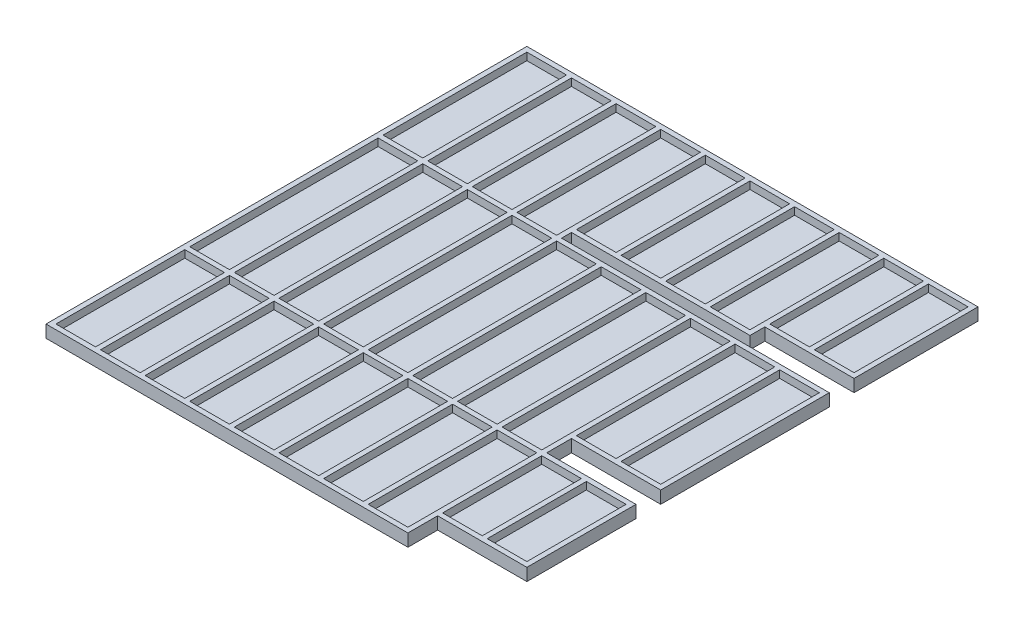
from build123d import *

# Parameters (mm, degrees)
EXTRUDE_2_DEPTH     = 2.5
CUT_EXTRUDE_START   = 1
SKETCH_2_W          = 8
SKETCH_2_H          = 29
SKETCH_2_H_2        = 26
SKETCH_2_H_3        = 38
SKETCH_2_H_4        = 23
SKETCH_2_H_5        = 32
SKETCH_2_H_6        = 20
CUT_EXTRUDE_2_DEPTH = 1.5


with BuildPart() as part:
    # 草图3 → 凸台-拉伸2 (new body)
    with BuildSketch(Plane(origin=(0, 0, 0), x_dir=(1, 0, 0), z_dir=(0, 1, 0))):
        Polygon((90, 1), (-1, 1), (-1, -96), (72, -96), (72, -90), (90, -90), (90, -68), (72, -68), (72, -63), (90, -63), (90, -29), (72, -29), (36, -29), (36, -27), (72, -27), (72, -24), (90, -24), align=None)
    extrude(amount=EXTRUDE_2_DEPTH)

    # 草图2 → 切除-拉伸2 (cut)
    with BuildSketch(Plane(origin=(0, 0, 0), x_dir=(1, 0, 0), z_dir=(0, 1, 0)).offset(CUT_EXTRUDE_START)):
        with Locations((4, -14.5)):
            Rectangle(SKETCH_2_W, SKETCH_2_H)
        with Locations((13, -14.5)):
            Rectangle(SKETCH_2_W, SKETCH_2_H)
        with Locations((22, -14.5)):
            Rectangle(SKETCH_2_W, SKETCH_2_H)
        with Locations((31, -14.5)):
            Rectangle(SKETCH_2_W, SKETCH_2_H)
        with Locations((40, -13)):
            Rectangle(SKETCH_2_W, SKETCH_2_H_2)
        with Locations((4, -49)):
            Rectangle(SKETCH_2_W, SKETCH_2_H_3)
        with Locations((4, -82)):
            Rectangle(SKETCH_2_W, SKETCH_2_H_2)
        with Locations((49, -13)):
            Rectangle(SKETCH_2_W, SKETCH_2_H_2)
        with Locations((58, -13)):
            Rectangle(SKETCH_2_W, SKETCH_2_H_2)
        with Locations((67, -13)):
            Rectangle(SKETCH_2_W, SKETCH_2_H_2)
        with Locations((76, -11.5)):
            Rectangle(SKETCH_2_W, SKETCH_2_H_4)
        with Locations((85, -11.5)):
            Rectangle(SKETCH_2_W, SKETCH_2_H_4)
        with Locations((13, -49)):
            Rectangle(SKETCH_2_W, SKETCH_2_H_3)
        with Locations((22, -49)):
            Rectangle(SKETCH_2_W, SKETCH_2_H_3)
        with Locations((31, -49)):
            Rectangle(SKETCH_2_W, SKETCH_2_H_3)
        with Locations((40, -49)):
            Rectangle(SKETCH_2_W, SKETCH_2_H_3)
        with Locations((49, -49)):
            Rectangle(SKETCH_2_W, SKETCH_2_H_3)
        with Locations((58, -49)):
            Rectangle(SKETCH_2_W, SKETCH_2_H_3)
        with Locations((67, -49)):
            Rectangle(SKETCH_2_W, SKETCH_2_H_3)
        with Locations((76, -46)):
            Rectangle(SKETCH_2_W, SKETCH_2_H_5)
        with Locations((85, -46)):
            Rectangle(SKETCH_2_W, SKETCH_2_H_5)
        with Locations((13, -82)):
            Rectangle(SKETCH_2_W, SKETCH_2_H_2)
        with Locations((22, -82)):
            Rectangle(SKETCH_2_W, SKETCH_2_H_2)
        with Locations((31, -82)):
            Rectangle(SKETCH_2_W, SKETCH_2_H_2)
        with Locations((40, -82)):
            Rectangle(SKETCH_2_W, SKETCH_2_H_2)
        with Locations((49, -82)):
            Rectangle(SKETCH_2_W, SKETCH_2_H_2)
        with Locations((58, -82)):
            Rectangle(SKETCH_2_W, SKETCH_2_H_2)
        with Locations((67, -82)):
            Rectangle(SKETCH_2_W, SKETCH_2_H_2)
        with Locations((76, -79)):
            Rectangle(SKETCH_2_W, SKETCH_2_H_6)
        with Locations((85, -79)):
            Rectangle(SKETCH_2_W, SKETCH_2_H_6)
    extrude(amount=CUT_EXTRUDE_2_DEPTH, mode=Mode.SUBTRACT)


solid = part.part
